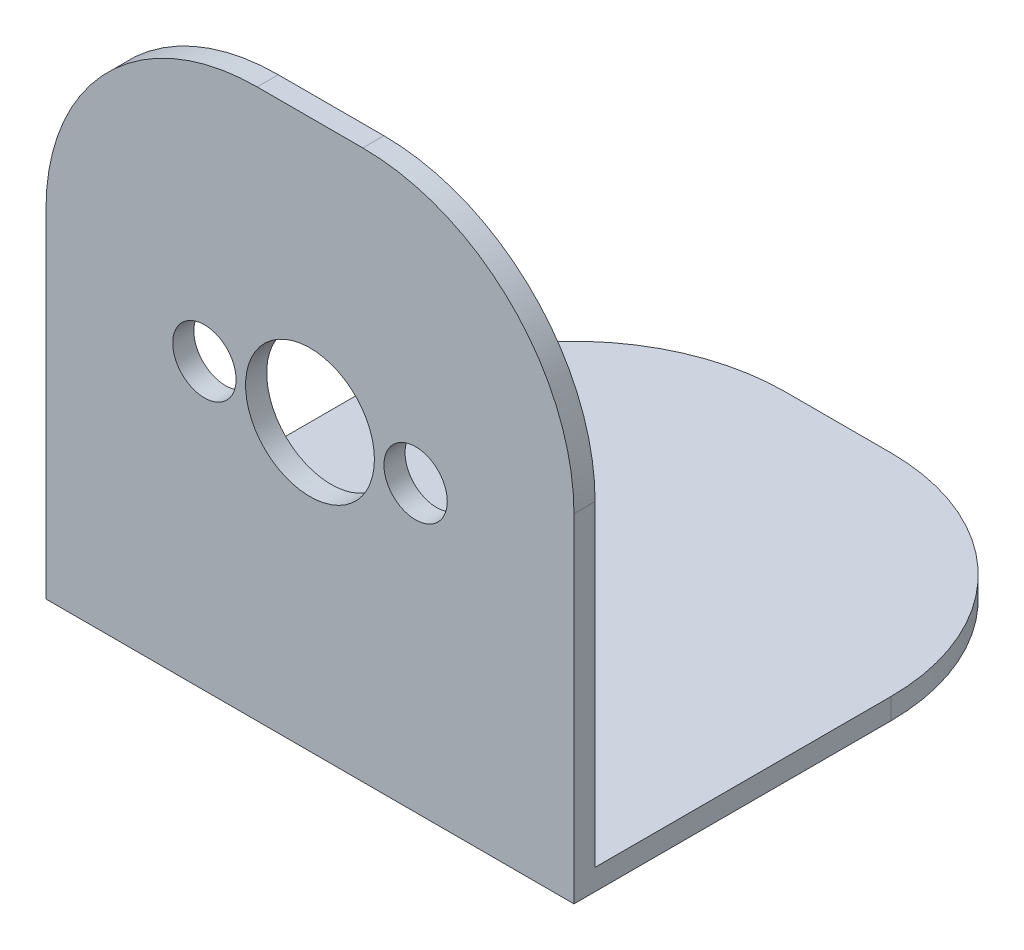
from build123d import *

# Parameters (mm, degrees)
SKETCH1_W      = 25
SKETCH1_H      = 25
SKETCH1_R      = 3.05
SKETCH1_R_2    = 1.5
EXTRUDE1_DEPTH = 1
SKETCH2_W      = 25
SKETCH2_H      = 25
EXTRUDE2_DEPTH = 1
FILLET1_R      = 10


with BuildPart() as part:
    # Sketch1 → Extrude1 (new body)
    with BuildSketch(Plane.XY):
        with Locations((12.5, 12.5)):
            Rectangle(SKETCH1_W, SKETCH1_H)
        with Locations((12.5, 12.5)):
            Circle(SKETCH1_R, mode=Mode.SUBTRACT)
        with Locations((17.5, 12.5)):
            Circle(SKETCH1_R_2, mode=Mode.SUBTRACT)
        with Locations((7.5, 12.5)):
            Circle(SKETCH1_R_2, mode=Mode.SUBTRACT)
    extrude(amount=EXTRUDE1_DEPTH)

    # Sketch2 → Extrude2 (add)
    with BuildSketch(Plane.XZ):
        with Locations((12.5, -11.5)):
            Rectangle(SKETCH2_W, SKETCH2_H)
    extrude(amount=EXTRUDE2_DEPTH)

    # Fillet1
    fillet1_edges = [part.edges().sort_by_distance(p)[0] for p in [
        (0, -0.5, -24),
        (25, -0.5, -24),
        (0, 25, 0.5),
        (25, 25, 0.5),
    ]]
    fillet(fillet1_edges, radius=FILLET1_R)


solid = part.part
